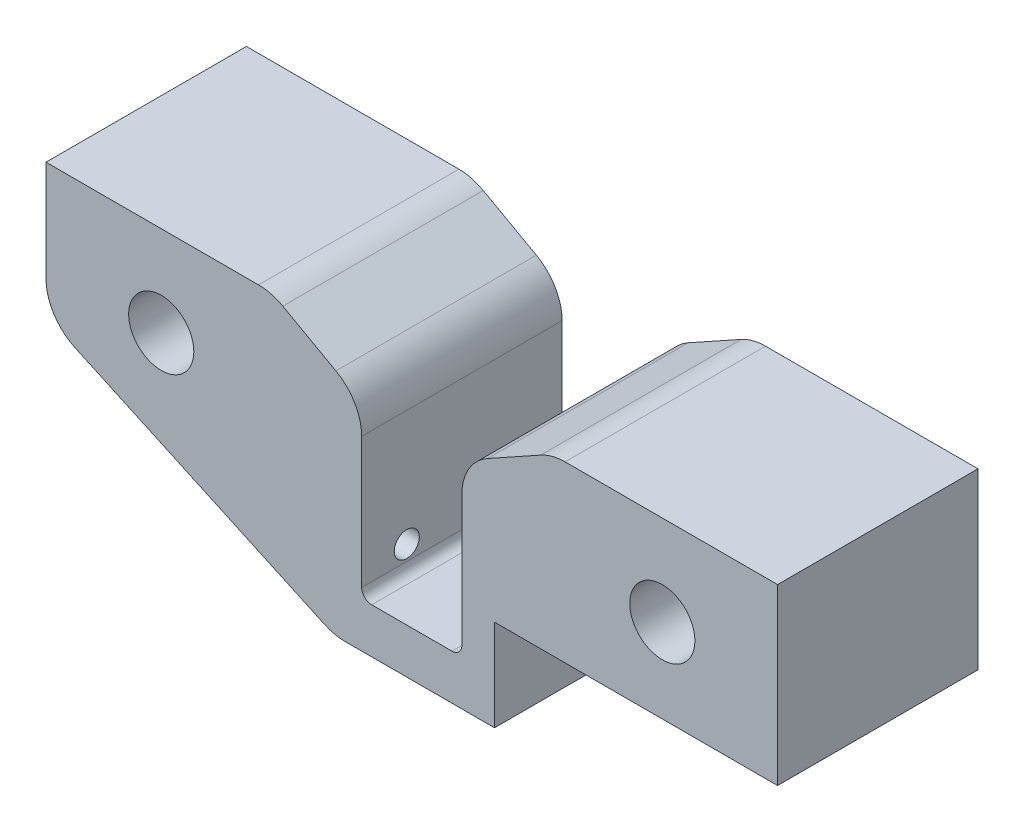
from build123d import *

# Parameters (mm, degrees)
SKETCH1_R               = 4.1275
BOSS_EXTRUDE1_DEPTH     = 25.4
SKETCH5_W               = 35.872468526
SKETCH5_H               = 11.596415725
CUT_EXTRUDE2_DEPTH      = 1
CUT_EXTRUDE2_DEPTH_BACK = 26.4
SKETCH6_R               = 1.5875
CUT_EXTRUDE3_DEPTH      = 20.32
CUT_EXTRUDE4_DEPTH      = 1
CUT_EXTRUDE4_DEPTH_BACK = 26.4
CUT_EXTRUDE5_DEPTH      = 34.655
CUT_EXTRUDE6_DEPTH      = 1
CUT_EXTRUDE6_DEPTH_BACK = 26.4
FILLET4_R               = 1.27
FILLET5_R               = 6.35
FILLET6_R               = 6.35


with BuildPart() as part:
    # Sketch1 → Boss-Extrude1 (new body)
    with BuildSketch(Plane.XY):
        Polygon((-46.355, 0), (46.355, 0), (46.355, 33.655), (6.35, 33.655), (6.35, 5.715), (-6.35, 5.715), (-6.35, 33.655), (-46.355, 33.655), align=None)
        with Locations((-31.75, 22.225)):
            Circle(SKETCH1_R, mode=Mode.SUBTRACT)
        with Locations((31.75, 22.225)):
            Circle(SKETCH1_R, mode=Mode.SUBTRACT)
    extrude(amount=BOSS_EXTRUDE1_DEPTH)

    # Sketch5 → Cut-Extrude2 (cut, two sides)
    with BuildSketch(Plane(origin=(0, 0, 0), x_dir=(-1, 0, 0), z_dir=(0, 0, -1))) as cut_extrude2_sk:
        with Locations((-28.418765737, 5.798207862)):
            Rectangle(SKETCH5_W, SKETCH5_H)
    extrude(amount=CUT_EXTRUDE2_DEPTH, mode=Mode.SUBTRACT)
    extrude(cut_extrude2_sk.sketch, amount=-CUT_EXTRUDE2_DEPTH_BACK, mode=Mode.SUBTRACT)

    # Sketch6 → Cut-Extrude3 (cut)
    with BuildSketch(Plane(origin=(10.482531474, 0, 0), x_dir=(0, 0, -1), z_dir=(1, 0, 0))):
        with Locations((-19.685, 8.89)):
            Circle(SKETCH6_R)
        with Locations((-5.715, 8.89)):
            Circle(SKETCH6_R)
    extrude(amount=-CUT_EXTRUDE3_DEPTH, mode=Mode.SUBTRACT)

    # Sketch9 → Cut-Extrude4 (cut, two sides)
    with BuildSketch(Plane(origin=(0, 0, 0), x_dir=(-1, 0, 0), z_dir=(0, 0, -1))) as cut_extrude4_sk:
        Polygon((-17.78, 33.655), (-6.35, 27.305), (-6.35, 33.655), align=None)
        Polygon((6.35, 27.305), (6.35, 33.655), (17.78, 33.655), align=None)
    extrude(amount=CUT_EXTRUDE4_DEPTH, mode=Mode.SUBTRACT)
    extrude(cut_extrude4_sk.sketch, amount=-CUT_EXTRUDE4_DEPTH_BACK, mode=Mode.SUBTRACT)

    # Sketch10 → Cut-Extrude5 (cut, through all)
    with BuildSketch(Plane.XZ):
        with BuildLine():
            ThreePointArc((0, 14.986), (-2.286, 12.7), (0, 10.414))
            Line((0, 10.414), (0, 14.986))
        make_face()
        with BuildLine():
            Line((0, 14.986), (0, 10.414))
            ThreePointArc((0, 10.414), (1.616446102, 11.083553898), (2.286, 12.7))
            ThreePointArc((2.286, 12.7), (1.616446102, 14.316446102), (0, 14.986))
        make_face()
    extrude(amount=-CUT_EXTRUDE5_DEPTH, mode=Mode.SUBTRACT)

    # Sketch11 → Cut-Extrude6 (cut, two sides)
    with BuildSketch(Plane(origin=(0, 0, 0), x_dir=(-1, 0, 0), z_dir=(0, 0, -1))) as cut_extrude6_sk:
        Polygon((9.811388306, 0), (46.355, 16.8275), (46.355, 0), align=None)
    extrude(amount=CUT_EXTRUDE6_DEPTH, mode=Mode.SUBTRACT)
    extrude(cut_extrude6_sk.sketch, amount=-CUT_EXTRUDE6_DEPTH_BACK, mode=Mode.SUBTRACT)

    # Fillet4
    fillet4_edges = [part.edges().sort_by_distance(p)[0] for p in [
        (-6.35, 5.715, 12.7),
        (6.35, 5.715, 12.7),
    ]]
    fillet(fillet4_edges, radius=FILLET4_R)

    # Fillet5
    fillet5_edges = [part.edges().sort_by_distance(p)[0] for p in [
        (17.78, 33.655, 12.7),
        (6.35, 27.305, 12.7),
        (-17.78, 33.655, 12.7),
        (-6.35, 27.305, 12.7),
    ]]
    fillet(fillet5_edges, radius=FILLET5_R)

    # Fillet6
    fillet6_edges = [part.edges().sort_by_distance(p)[0] for p in [
        (-9.811388306, 0, 12.7),
        (-46.355, 16.8275, 12.7),
    ]]
    fillet(fillet6_edges, radius=FILLET6_R)


solid = part.part
